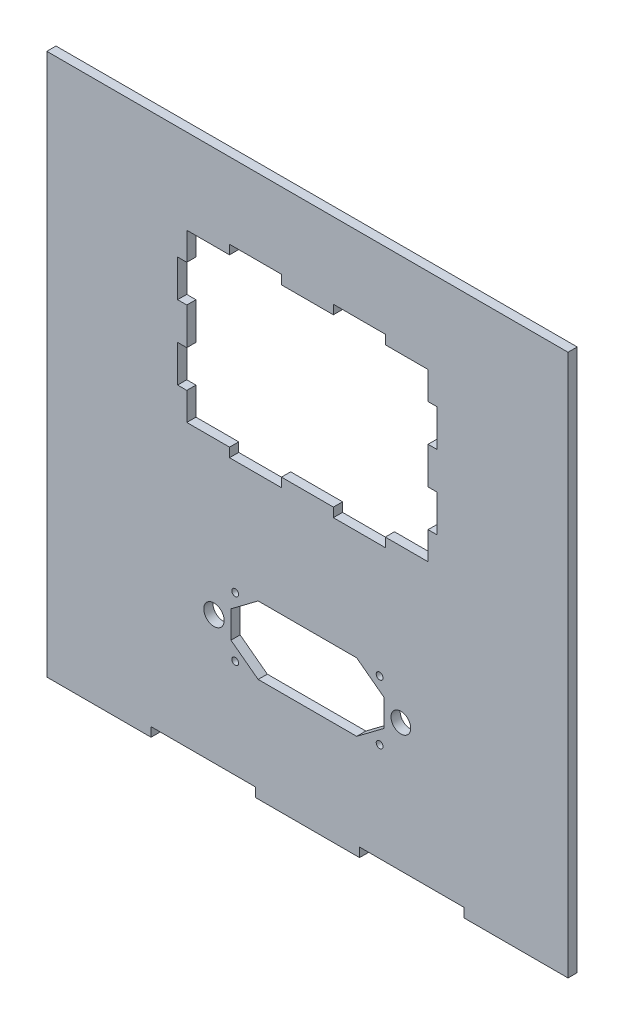
from build123d import *

# Parameters (mm, degrees)
SKETCH1_R           = 1
SKETCH1_R_2         = 3
SKETCH1_R_3         = 2.9
BOSS_EXTRUDE3_DEPTH = 2.7


with BuildPart() as part:
    # Sketch1 → Boss-Extrude3 (new body)
    with BuildSketch(Plane.XY):
        Polygon((-46.02, -28), (-46.02, -25.3), (-15.34, -25.3), (-15.34, -28), (15.34, -28), (15.34, -25.3), (46.02, -25.3), (46.02, -28), (76.7, -28), (76.7, -25.3), (76.7, -23), (76.7, 13), (76.7, 131.5), (-76.7, 131.5), (-76.7, 13), (-76.7, -23), (-76.7, -25.3), (-76.7, -28), align=None)
        with Locations((-21.25, 3.75)):
            Circle(SKETCH1_R, mode=Mode.SUBTRACT)
        with Locations((-27.5, 12.5)):
            Circle(SKETCH1_R_2, mode=Mode.SUBTRACT)
        with Locations((-21.25, 21.25)):
            Circle(SKETCH1_R, mode=Mode.SUBTRACT)
        with Locations((21.25, 3.75)):
            Circle(SKETCH1_R, mode=Mode.SUBTRACT)
        with Locations((27.5, 12.5)):
            Circle(SKETCH1_R_3, mode=Mode.SUBTRACT)
        with Locations((21.25, 21.25)):
            Circle(SKETCH1_R, mode=Mode.SUBTRACT)
        Polygon((-22.5, 16.5), (-14.5, 22.5), (14.5, 22.5), (22.5, 16.5), (22.5, 8.5), (14.5, 2.5), (0, 2.5), (-14.5, 2.5), (-22.5, 8.5), align=None, mode=Mode.SUBTRACT)
        Polygon((35.5, 57.5), (22.92, 57.5), (22.92, 54.8), (7.64, 54.8), (7.64, 57.5), (-7.64, 57.5), (-7.64, 54.8), (-22.92, 54.8), (-22.92, 57.5), (-35.5, 57.5), (-35.5, 65.68), (-38.2, 65.68), (-38.2, 76.56), (-35.5, 76.56), (-35.5, 87.44), (-38.2, 87.44), (-38.2, 98.32), (-35.5, 98.32), (-35.5, 106.5), (-22.92, 106.5), (-22.92, 109.2), (-7.64, 109.2), (-7.64, 106.5), (7.64, 106.5), (7.64, 109.2), (22.92, 109.2), (22.92, 106.5), (35.5, 106.5), (35.5, 98.32), (38.2, 98.32), (38.2, 87.44), (35.5, 87.44), (35.5, 76.56), (38.2, 76.56), (38.2, 65.68), (35.5, 65.68), align=None, mode=Mode.SUBTRACT)
    extrude(amount=BOSS_EXTRUDE3_DEPTH)


solid = part.part
